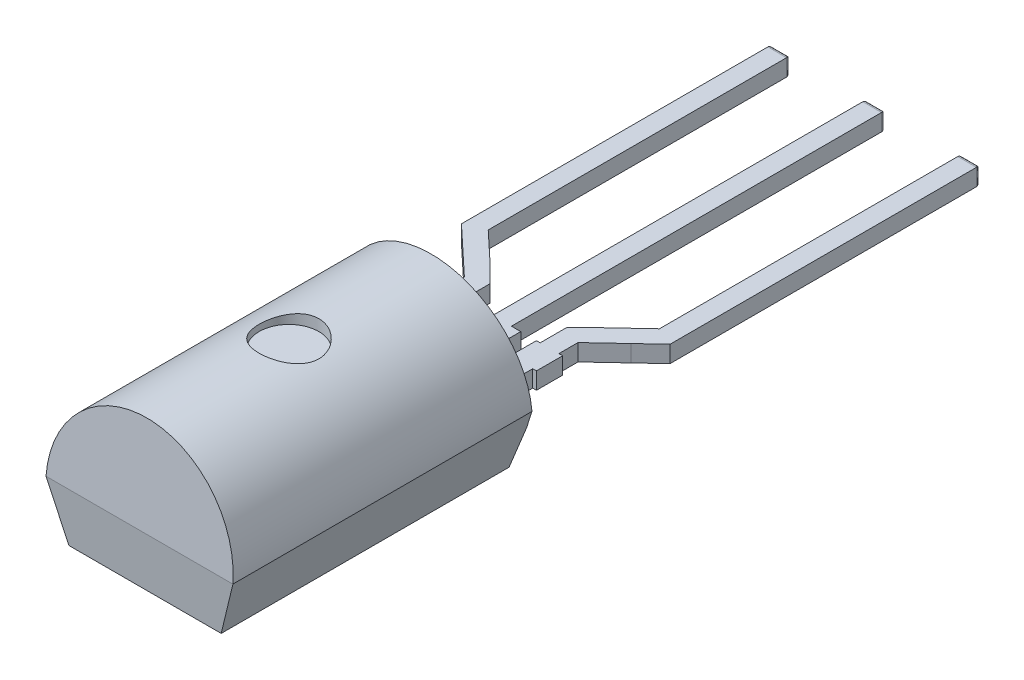
from build123d import *

# Parameters (mm, degrees)
BOSS_EXTRUDE2_DEPTH = 8
BOSS_EXTRUDE3_DEPTH = 0.225
BOSS_EXTRUDE4_DEPTH = 0.225
BOSS_EXTRUDE7_DEPTH = 0.225
BOSS_EXTRUDE8_DEPTH = 0.225
CUT_EXTRUDE1_DEPTH  = 5
CUT_EXTRUDE2_DEPTH  = 5
CUT_EXTRUDE3_DEPTH  = 5
CUT_EXTRUDE7_DEPTH  = 5
FILLET2_R           = 0.1
SKETCH13_R          = 0.8
CUT_EXTRUDE8_DEPTH  = 0.3


with BuildPart() as part:
    # Sketch1 → Boss-Extrude2 (new body)
    with BuildSketch(Plane.XY):
        with BuildLine():
            Line((-2.036541185, -1.45), (2.036541185, -1.45))
            Line((2.036541185, -1.45), (2.5, 0))
            ThreePointArc((2.5, 0), (0, 2.5), (-2.5, 0))
            Line((-2.5, 0), (-2.036541185, -1.45))
        make_face()
    extrude(amount=BOSS_EXTRUDE2_DEPTH)

    # Sketch3 → Boss-Extrude3 (add)
    with BuildSketch(Plane(origin=(0, -0.225, 0), x_dir=(1, 0, 0), z_dir=(0, 1, 0))):
        Polygon((-0.4, 0), (0.4, 0), (0.4, 1), (0.5, 1), (0.5, 1.7), (0.25, 1.7), (0.25, 11.7), (-0.25, 11.7), (-0.25, 1.7), (-0.5, 1.7), (-0.5, 1), (-0.4, 1), align=None)
    extrude(amount=BOSS_EXTRUDE3_DEPTH)

    # Sketch3_3 → Boss-Extrude4 (add)
    with BuildSketch(Plane(origin=(0, -0.225, 0), x_dir=(1, 0, 0), z_dir=(0, 1, 0))):
        Polygon((-0.4, 0), (0.4, 0), (0.4, 1), (0.5, 1), (0.5, 1.7), (0.25, 1.7), (0.25, 11.7), (-0.25, 11.7), (-0.25, 1.7), (-0.5, 1.7), (-0.5, 1), (-0.4, 1), align=None)
    extrude(amount=-BOSS_EXTRUDE4_DEPTH)

    # Sketch7 → Boss-Extrude7 (add)
    with BuildSketch(Plane(origin=(0, -0.225, 0), x_dir=(1, 0, 0), z_dir=(0, 1, 0))):
        Polygon((1.02, 1), (1.02, 0), (1.27, 0), (1.52, 0), (1.52, 1), (1.62, 1), (1.62, 1.7), (1.52, 1.7), (1.52, 2.211954512), (2.250085443, 2.896837591), (2.249444332, 2.897521015), (2.250813973, 2.897521015), (2.29, 2.934280887), (2.79, 3.403323987), (2.79, 4.08889049), (2.79, 11.7), (2.29, 11.7), (2.29, 3.61984739), (1.52, 2.897521015), (1.02, 2.397521015), (1.02, 2.211954512), (1.02, 1.7), (0.92, 1.7), (0.92, 1), align=None)
    boss_extrude7 = extrude(amount=BOSS_EXTRUDE7_DEPTH)

    # Sketch7_7 → Boss-Extrude8 (add)
    with BuildSketch(Plane(origin=(0, -0.225, 0), x_dir=(1, 0, 0), z_dir=(0, 1, 0))):
        Polygon((1.02, 1), (1.02, 0), (1.27, 0), (1.52, 0), (1.52, 1), (1.62, 1), (1.62, 1.7), (1.52, 1.7), (1.52, 2.211954512), (2.250085443, 2.896837591), (2.249444332, 2.897521015), (2.250813973, 2.897521015), (2.29, 2.934280887), (2.79, 3.403323987), (2.79, 4.08889049), (2.79, 11.7), (2.29, 11.7), (2.29, 3.61984739), (1.52, 2.897521015), (1.02, 2.397521015), (1.02, 2.211954512), (1.02, 1.7), (0.92, 1.7), (0.92, 1), align=None)
    boss_extrude8 = extrude(amount=-BOSS_EXTRUDE8_DEPTH)

    # Mirror2: Boss-Extrude7, Boss-Extrude8 across plane
    add(boss_extrude7.mirror(Plane(origin=(0, 0, 0), x_dir=(0, 0, 1), z_dir=(1, 0, 0))))
    add(boss_extrude8.mirror(Plane(origin=(0, 0, 0), x_dir=(0, 0, 1), z_dir=(1, 0, 0))))

    # Sketch9 → Cut-Extrude1 (cut)
    with BuildSketch(Plane(origin=(2.5, 0, 0), x_dir=(0, 0, -1), z_dir=(1, 0, 0))):
        Polygon((-8, 0), (-7.8, 2.5), (-8, 2.5), align=None)
    extrude(amount=-CUT_EXTRUDE1_DEPTH, mode=Mode.SUBTRACT)

    # Sketch10 → Cut-Extrude2 (cut)
    with BuildSketch(Plane(origin=(2.5, 0, 0), x_dir=(0, 0, -1), z_dir=(1, 0, 0))):
        Polygon((-8, 0), (-8, -1.45), (-7.85, -1.45), align=None)
    extrude(amount=-CUT_EXTRUDE2_DEPTH, mode=Mode.SUBTRACT)

    # Sketch11 → Cut-Extrude3 (cut)
    with BuildSketch(Plane(origin=(2.5, 0, 0), x_dir=(0, 0, -1), z_dir=(1, 0, 0))):
        Polygon((-0.2, 2.5), (0, 0), (0, 2.5), align=None)
    extrude(amount=-CUT_EXTRUDE3_DEPTH, mode=Mode.SUBTRACT)

    # Sketch12 → Cut-Extrude7 (cut)
    with BuildSketch(Plane(origin=(2.5, 0, 0), x_dir=(0, 0, -1), z_dir=(1, 0, 0))):
        Polygon((0, -0.45), (0, -1.45), (-0.15, -1.45), align=None)
    extrude(amount=-CUT_EXTRUDE7_DEPTH, mode=Mode.SUBTRACT)

    # Fillet2
    fillet2_edges = [part.edges().sort_by_distance(p)[0] for p in [
        (2.54, 0, -11.7),
        (2.29, -0.225, -11.7),
        (2.54, -0.45, -11.7),
        (2.79, -0.225, -11.7),
        (-2.54, 0, -11.7),
        (-2.79, -0.225, -11.7),
        (-2.54, -0.45, -11.7),
        (-2.29, -0.225, -11.7),
        (0, -0.45, -11.7),
        (0.25, -0.225, -11.7),
        (-0.25, -0.225, -11.7),
        (0, 0, -11.7),
    ]]
    fillet(fillet2_edges, radius=FILLET2_R)

    # Sketch13 → Cut-Extrude8 (cut)
    with BuildSketch(Plane(origin=(0, 2.5, 0), x_dir=(1, 0, 0), z_dir=(0, 1, 0))):
        with Locations((0, -4)):
            Circle(SKETCH13_R)
    extrude(amount=-CUT_EXTRUDE8_DEPTH, mode=Mode.SUBTRACT)


solid = part.part
